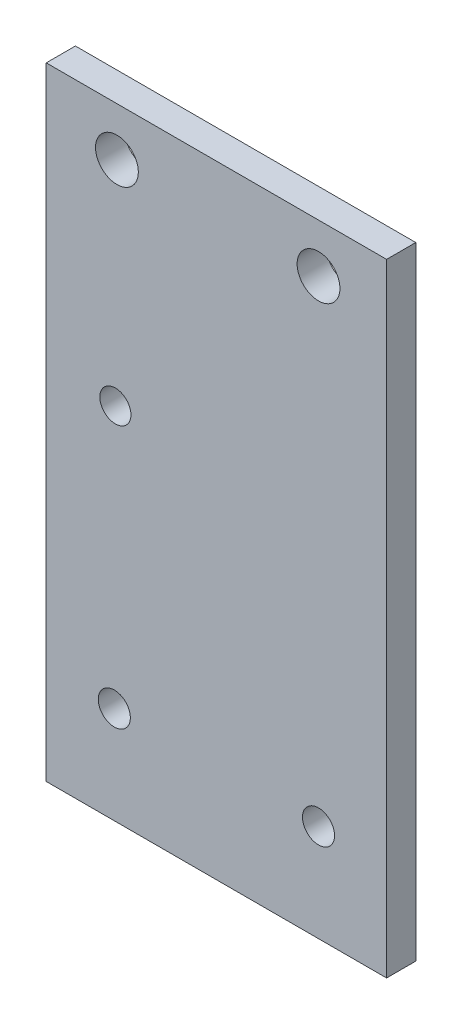
from build123d import *

# Parameters (mm, degrees)
SKETCH_1_W           = 40
SKETCH_1_H           = 29
EXTRUDE_1_DEPTH      = 3
CUT_EXTRUDE_1_DEPTH  = 3
SKETCH_3_W           = 40
SKETCH_3_H           = 3
EXTRUDE_2_DEPTH      = 10
SKETCH_4_W           = 40
SKETCH_4_H           = 3
EXTRUDE_3_DEPTH      = 10
SKETCH_6_W           = 3
SKETCH_6_H           = 49
EXTRUDE_5_DEPTH      = 42
SKETCH_8_W           = 3
SKETCH_8_H           = 49
EXTRUDE_6_DEPTH      = 2
SKETCH_9_W           = 3
SKETCH_9_H           = 49
EXTRUDE_7_DEPTH      = 2
SKETCH_10_W          = 86
SKETCH_10_H          = 3
EXTRUDE_8_DEPTH      = 10
SKETCH_11_W          = 86
SKETCH_11_H          = 3
EXTRUDE_9_DEPTH      = 10
SKETCH_14_W          = 3
SKETCH_14_H          = 69
CUT_EXTRUDE_5_DEPTH  = 43
SKETCH_17_W          = 43
SKETCH_17_H          = 3
EXTRUDE_10_DEPTH     = 20
SKETCH_20_W          = 43
SKETCH_20_H          = 3
EXTRUDE_11_DEPTH     = 10
SKETCH_21_W          = 43
SKETCH_21_H          = 3
CUT_EXTRUDE_7_DEPTH  = 20
SKETCH_24_R          = 2.2
CUT_EXTRUDE_8_DEPTH  = 30
SKETCH_26_R          = 1.6
CUT_EXTRUDE_9_DEPTH  = 10
SKETCH_27_W          = 3
SKETCH_27_H          = 79
CUT_EXTRUDE_10_DEPTH = 8
SKETCH_28_W          = 35
SKETCH_28_H          = 3
CUT_EXTRUDE_11_DEPTH = 15
CUT_EXTRUDE_13_DEPTH = 10
M4X0_7_3_D           = 3.3


with BuildPart() as part:
    # ｽｹｯﾁ1 → ﾎﾞｽ - 押し出し1 (new body)
    with BuildSketch(Plane.XY):
        Rectangle(SKETCH_1_W, SKETCH_1_H)
    extrude(amount=EXTRUDE_1_DEPTH)

    # ｽｹｯﾁ2 → ｶｯﾄ - 押し出し1 (cut)
    with BuildSketch(Plane.XY.offset(3)):
        with BuildLine():
            ThreePointArc((-14.4, 10.5), (-15.01507576, 11.98492424), (-16.5, 12.6))
            Line((-16.5, 12.6), (-16.5, 10.5))
            Line((-16.5, 10.5), (-18.6, 10.5))
            ThreePointArc((-18.6, 10.5), (-16.5, 8.4), (-14.4, 10.5))
        make_face()
        with BuildLine():
            Line((-16.5, 10.5), (-16.5, 12.6))
            ThreePointArc((-16.5, 12.6), (-17.98492424, 11.98492424), (-18.6, 10.5))
            Line((-18.6, 10.5), (-16.5, 10.5))
        make_face()
        with BuildLine():
            ThreePointArc((-18.6, -10.5), (-17.98492424, -11.98492424), (-16.5, -12.6))
            Line((-16.5, -12.6), (-16.5, -10.5))
            Line((-16.5, -10.5), (-18.6, -10.5))
        make_face()
        with BuildLine():
            Line((-16.5, -10.5), (-16.5, -12.6))
            ThreePointArc((-16.5, -12.6), (-15.01507576, -11.98492424), (-14.4, -10.5))
            ThreePointArc((-14.4, -10.5), (-16.5, -8.4), (-18.6, -10.5))
            Line((-18.6, -10.5), (-16.5, -10.5))
        make_face()
        with BuildLine():
            ThreePointArc((18.6, -10.5), (15.01507576, -9.01507576), (16.5, -12.6))
            Line((16.5, -12.6), (16.5, -10.5))
            Line((16.5, -10.5), (18.6, -10.5))
        make_face()
        with BuildLine():
            Line((16.5, -10.5), (16.5, -12.6))
            ThreePointArc((16.5, -12.6), (17.98492424, -11.98492424), (18.6, -10.5))
            Line((18.6, -10.5), (16.5, -10.5))
        make_face()
        with BuildLine():
            ThreePointArc((18.6, 10.5), (17.98492424, 11.98492424), (16.5, 12.6))
            Line((16.5, 12.6), (16.5, 10.5))
            Line((16.5, 10.5), (18.6, 10.5))
        make_face()
        with BuildLine():
            Line((16.5, 10.5), (16.5, 12.6))
            ThreePointArc((16.5, 12.6), (15.01507576, 9.01507576), (18.6, 10.5))
            Line((18.6, 10.5), (16.5, 10.5))
        make_face()
    extrude(amount=-CUT_EXTRUDE_1_DEPTH, mode=Mode.SUBTRACT)

    # ｽｹｯﾁ3 → ﾎﾞｽ - 押し出し2 (add)
    with BuildSketch(Plane.XZ.offset(14.5)):
        with Locations((0, 1.5)):
            Rectangle(SKETCH_3_W, SKETCH_3_H)
    extrude(amount=EXTRUDE_2_DEPTH)

    # ｽｹｯﾁ4 → ﾎﾞｽ - 押し出し3 (add)
    with BuildSketch(Plane(origin=(0, 14.5, 0), x_dir=(1, 0, 0), z_dir=(0, 1, 0))):
        with Locations((0, -1.5)):
            Rectangle(SKETCH_4_W, SKETCH_4_H)
    extrude(amount=EXTRUDE_3_DEPTH)

    # ｽｹｯﾁ6 → ﾎﾞｽ - 押し出し5 (add)
    with BuildSketch(Plane(origin=(20, 0, 0), x_dir=(0, 0, -1), z_dir=(1, 0, 0))):
        with Locations((-1.5, 0)):
            Rectangle(SKETCH_6_W, SKETCH_6_H)
    extrude(amount=EXTRUDE_5_DEPTH)

    # ｽｹｯﾁ8 → ﾎﾞｽ - 押し出し6 (add)
    with BuildSketch(Plane.ZY.offset(20)):
        with Locations((1.5, 0)):
            Rectangle(SKETCH_8_W, SKETCH_8_H)
    extrude(amount=EXTRUDE_6_DEPTH)

    # ｽｹｯﾁ9 → ﾎﾞｽ - 押し出し7 (add)
    with BuildSketch(Plane(origin=(62, 0, 0), x_dir=(0, 0, -1), z_dir=(1, 0, 0))):
        with Locations((-1.5, 0)):
            Rectangle(SKETCH_9_W, SKETCH_9_H)
    extrude(amount=EXTRUDE_7_DEPTH)

    # ｽｹｯﾁ10 → ﾎﾞｽ - 押し出し8 (add)
    with BuildSketch(Plane.XZ.offset(24.5)):
        with Locations((21, 1.5)):
            Rectangle(SKETCH_10_W, SKETCH_10_H)
    extrude(amount=EXTRUDE_8_DEPTH)

    # ｽｹｯﾁ11 → ﾎﾞｽ - 押し出し9 (add)
    with BuildSketch(Plane(origin=(0, 24.5, 0), x_dir=(1, 0, 0), z_dir=(0, 1, 0))):
        with Locations((21, -1.5)):
            Rectangle(SKETCH_11_W, SKETCH_11_H)
    extrude(amount=EXTRUDE_9_DEPTH)

    # ｽｹｯﾁ14 → ｶｯﾄ - 押し出し5 (cut)
    with BuildSketch(Plane.ZY.offset(22)):
        with Locations((1.5, 0)):
            Rectangle(SKETCH_14_W, SKETCH_14_H)
    extrude(amount=-CUT_EXTRUDE_5_DEPTH, mode=Mode.SUBTRACT)

    # ｽｹｯﾁ17 → ﾎﾞｽ - 押し出し10 (add)
    with BuildSketch(Plane.XZ.offset(34.5)):
        with Locations((42.5, 1.5)):
            Rectangle(SKETCH_17_W, SKETCH_17_H)
    extrude(amount=EXTRUDE_10_DEPTH)

    # ｽｹｯﾁ20 → ﾎﾞｽ - 押し出し11 (add)
    with BuildSketch(Plane.XZ.offset(54.5)):
        with Locations((42.5, 1.5)):
            Rectangle(SKETCH_20_W, SKETCH_20_H)
    extrude(amount=EXTRUDE_11_DEPTH)

    # ｽｹｯﾁ21 → ｶｯﾄ - 押し出し7 (cut)
    with BuildSketch(Plane.XZ.offset(64.5)):
        with Locations((42.5, 1.5)):
            Rectangle(SKETCH_21_W, SKETCH_21_H)
    extrude(amount=-CUT_EXTRUDE_7_DEPTH, mode=Mode.SUBTRACT)

    # ｽｹｯﾁ24 → ｶｯﾄ - 押し出し8 (cut)
    with BuildSketch(Plane(origin=(0, 0, 0), x_dir=(-1, 0, 0), z_dir=(0, 0, -1))):
        with Locations((-36.27, 14.5)):
            Circle(SKETCH_24_R)
        with Locations((-57, 14.5)):
            Circle(SKETCH_24_R)
    extrude(amount=-CUT_EXTRUDE_8_DEPTH, mode=Mode.SUBTRACT)

    # ｽｹｯﾁ26 → ｶｯﾄ - 押し出し9 (cut)
    with BuildSketch(Plane(origin=(0, 0, 0), x_dir=(-1, 0, 0), z_dir=(0, 0, -1))):
        with Locations((-36.11, -7.5)):
            Circle(SKETCH_26_R)
    extrude(amount=-CUT_EXTRUDE_9_DEPTH, mode=Mode.SUBTRACT)

    # ｽｹｯﾁ27 → ｶｯﾄ - 押し出し10 (cut)
    with BuildSketch(Plane.ZY.offset(-21)):
        with Locations((1.5, -5)):
            Rectangle(SKETCH_27_W, SKETCH_27_H)
    extrude(amount=-CUT_EXTRUDE_10_DEPTH, mode=Mode.SUBTRACT)

    # ｽｹｯﾁ28 → ｶｯﾄ - 押し出し11 (cut)
    with BuildSketch(Plane(origin=(0, 34.5, 0), x_dir=(1, 0, 0), z_dir=(0, 1, 0))):
        with Locations((46.5, -1.5)):
            Rectangle(SKETCH_28_W, SKETCH_28_H)
    extrude(amount=-CUT_EXTRUDE_11_DEPTH, mode=Mode.SUBTRACT)

    # ｽｹｯﾁ33 → ｶｯﾄ - 押し出し13 (cut)
    with BuildSketch(Plane(origin=(0, 0, 0), x_dir=(-1, 0, 0), z_dir=(0, 0, -1))):
        with BuildLine():
            ThreePointArc((-35, -34.5), (-36.707106781, -33.792893219), (-36, -35.5))
            Line((-36, -35.5), (-36, -34.5))
            Line((-36, -34.5), (-35, -34.5))
        make_face()
        with BuildLine():
            Line((-36, -34.5), (-36, -35.5))
            ThreePointArc((-36, -35.5), (-35.292893219, -35.207106781), (-35, -34.5))
            Line((-35, -34.5), (-36, -34.5))
        make_face()
        with BuildLine():
            ThreePointArc((-58, -34.5), (-57.707106781, -35.207106781), (-57, -35.5))
            Line((-57, -35.5), (-57, -34.5))
            Line((-57, -34.5), (-58, -34.5))
        make_face()
        with BuildLine():
            Line((-57, -34.5), (-57, -35.5))
            ThreePointArc((-57, -35.5), (-56.292893219, -35.207106781), (-56, -34.5))
            ThreePointArc((-56, -34.5), (-57, -33.5), (-58, -34.5))
            Line((-58, -34.5), (-57, -34.5))
        make_face()
    extrude(amount=-CUT_EXTRUDE_13_DEPTH, mode=Mode.SUBTRACT)

    # M4x0.7 ねじ穴3 (through all)
    with Locations(Plane(origin=(36, -34.5, 0), x_dir=(-1, 0, 0), z_dir=(0, 0, -1))):
        with Locations((0, 0), (-21, 0)):
            Hole(M4X0_7_3_D / 2)


solid = part.part
